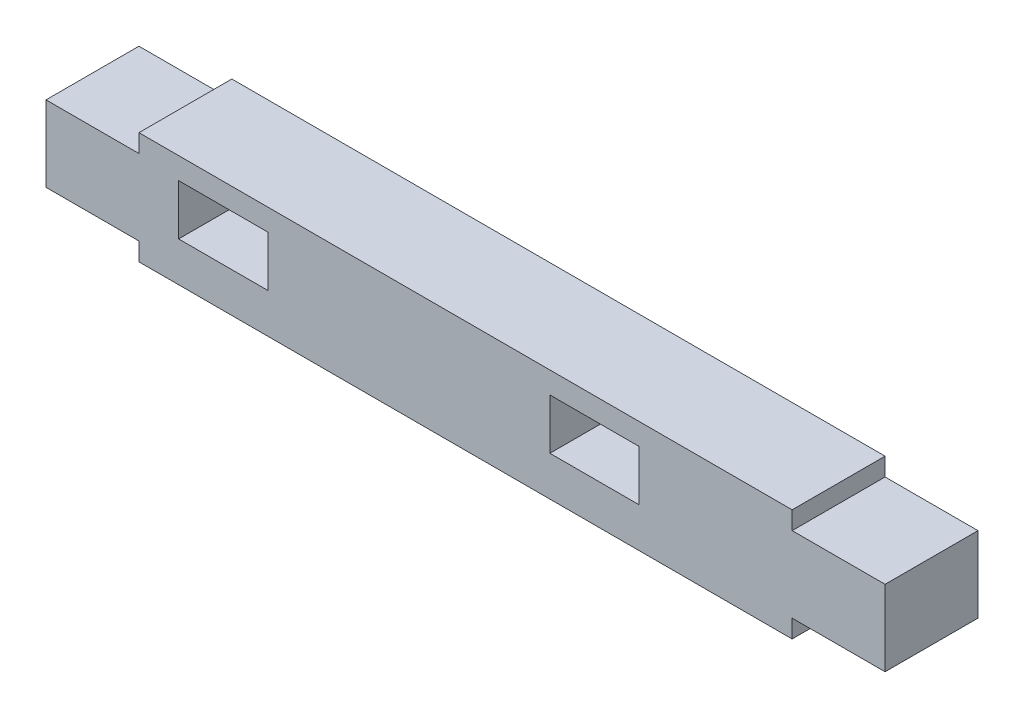
from build123d import *

# Parameters (mm, degrees)
BOSS_EXTRUDE1_DEPTH = 5.15
SKETCH3_W           = 4.95
SKETCH3_H           = 2.8
CUT_EXTRUDE1_DEPTH  = 6.15


with BuildPart() as part:
    # Sketch1 → Boss-Extrude1 (new body)
    with BuildSketch(Plane.XY):
        Polygon((-18.1, 6.1), (18.1, 6.1), (18.1, 5.1), (23.25, 5.1), (23.25, 0.9), (18.1, 0.9), (18.1, -0.1), (-18.1, -0.1), (-18.1, 0.9), (-23.25, 0.9), (-23.25, 5.1), (-18.1, 5.1), align=None)
    extrude(amount=BOSS_EXTRUDE1_DEPTH)

    # Sketch3 → Cut-Extrude1 (cut, through all)
    with BuildSketch(Plane.XY.offset(5.15)):
        with Locations((7.15, 3.5)):
            Rectangle(SKETCH3_W, SKETCH3_H)
        with Locations((-13.425, 3.5)):
            Rectangle(SKETCH3_W, SKETCH3_H)
    extrude(amount=-CUT_EXTRUDE1_DEPTH, mode=Mode.SUBTRACT)


solid = part.part
